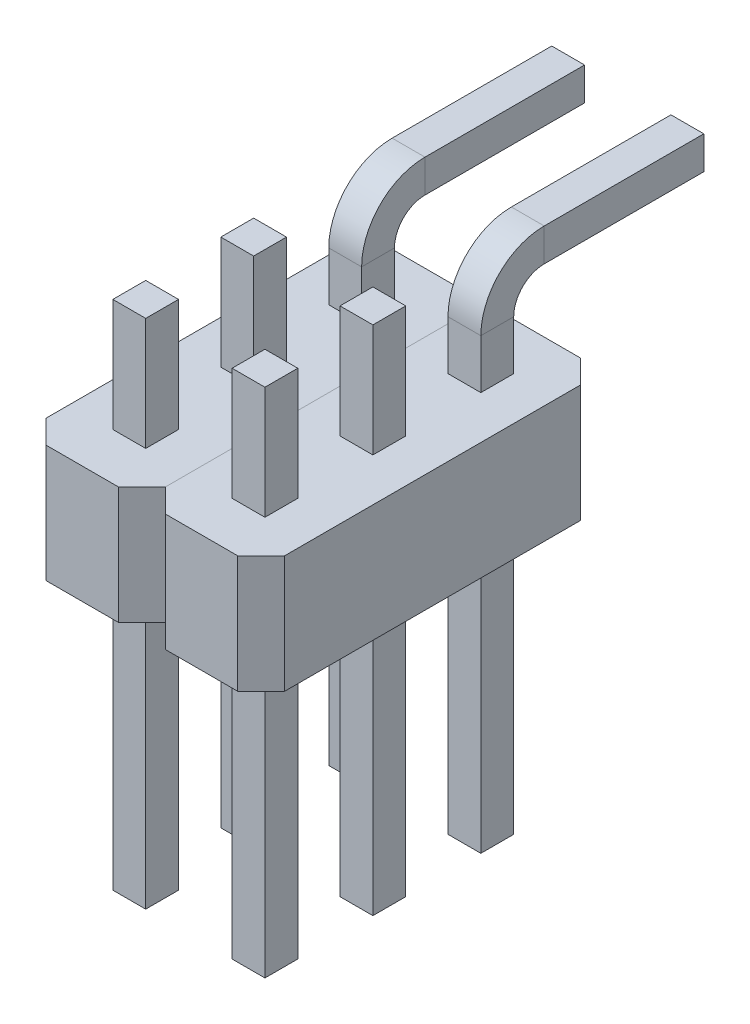
from build123d import *

# Parameters (mm, degrees)
SKETCH1_W           = 0.7
SKETCH1_H           = 0.7
SKETCH1_5_W         = 0.7
SKETCH1_5_H         = 0.7
SKETCH1_6_W         = 0.7
SKETCH1_6_H         = 0.7
SKETCH1_7_W         = 2.54
SKETCH1_7_H         = 7.3
SKETCH1_7_W_2       = 0.7
SKETCH1_7_H_2       = 0.7
BOSS_EXTRUDE1_DEPTH = 2.5
CHAMFER1_SIZE       = 0.5
LPATTERN1_COUNT     = 2
LPATTERN1_PITCH     = 2.54
SKETCH3_W           = 5.08
SKETCH3_H           = 10.35
CUT_EXTRUDE1_DEPTH  = 15.067920955


with BuildPart() as part:
    # Sweep3: sweep along a path in Sketch2
    with BuildLine(Plane(origin=(1.25, 0, 0), x_dir=(0, 0, -1), z_dir=(1, 0, 0))) as sweep3_path:
        Line((-5.95, -6), (-5.95, 8.15))
        ThreePointArc((-5.95, 8.15), (-5.657106781, 8.857106781), (-4.95, 9.15))
        Line((-4.95, 9.15), (3.05, 9.15))
    # Sketch1 → Sweep3 (sweep)
    with BuildSketch(Plane(origin=(0, 0, 0), x_dir=(1, 0, 0), z_dir=(0, 1, 0))):
        with Locations((1.27, -5.95)):
            Rectangle(SKETCH1_W, SKETCH1_H)
    sweep(path=sweep3_path.line)



with BuildPart() as body_2:
    # Sweep4: sweep along a path in Sketch2_6
    with BuildLine(Plane(origin=(1.25, 0, 0), x_dir=(0, 0, -1), z_dir=(1, 0, 0))) as sweep4_path:
        Line((-3.65, -6), (-3.65, 5.85))
        ThreePointArc((-3.65, 5.85), (-3.357106781, 6.557106781), (-2.65, 6.85))
        Line((-2.65, 6.85), (3.05, 6.85))
    # Sketch1_5 → Sweep4 (sweep)
    with BuildSketch(Plane(origin=(0, 0, 0), x_dir=(1, 0, 0), z_dir=(0, 1, 0))):
        with Locations((1.27, -3.65)):
            Rectangle(SKETCH1_5_W, SKETCH1_5_H)
    sweep(path=sweep4_path.line)


with BuildPart() as body_3:
    # Sweep5: sweep along a path in Sketch2_7
    with BuildLine(Plane(origin=(1.25, 0, 0), x_dir=(0, 0, -1), z_dir=(1, 0, 0))) as sweep5_path:
        Line((-1.35, -6), (-1.35, 3.55))
        ThreePointArc((-1.35, 3.55), (-1.057106781, 4.257106781), (-0.35, 4.55))
        Line((-0.35, 4.55), (3.05, 4.55))
    # Sketch1_6 → Sweep5 (sweep)
    with BuildSketch(Plane(origin=(0, 0, 0), x_dir=(1, 0, 0), z_dir=(0, 1, 0))):
        with Locations((1.27, -1.35)):
            Rectangle(SKETCH1_6_W, SKETCH1_6_H)
    sweep(path=sweep5_path.line)


with BuildPart() as part_1:
    add(part.part)

    add(body_2.part)  # Boss-Extrude1 merges body 2

    add(body_3.part)  # Boss-Extrude1 merges body 3
    # Sketch1_7 → Boss-Extrude1 (add)
    with BuildSketch(Plane(origin=(0, 0, 0), x_dir=(1, 0, 0), z_dir=(0, 1, 0))):
        with Locations((1.27, -3.65)):
            Rectangle(SKETCH1_7_W, SKETCH1_7_H)
        with Locations((1.27, -5.95)):
            Rectangle(SKETCH1_7_W_2, SKETCH1_7_H_2, mode=Mode.SUBTRACT)
        with Locations((1.27, -3.65)):
            Rectangle(SKETCH1_7_W_2, SKETCH1_7_H_2, mode=Mode.SUBTRACT)
        with Locations((1.27, -1.35)):
            Rectangle(SKETCH1_7_W_2, SKETCH1_7_H_2, mode=Mode.SUBTRACT)
    extrude(amount=BOSS_EXTRUDE1_DEPTH)

    # Chamfer1
    chamfer1_edges = [part_1.edges().sort_by_distance(p)[0] for p in [
        (0, 1.25, 0),
        (2.54, 1.25, 0),
        (0, 1.25, 7.3),
        (2.54, 1.25, 7.3),
    ]]
    chamfer(chamfer1_edges, length=CHAMFER1_SIZE)


with BuildPart() as lpattern1_1:
    # LPattern1: pattern copy
    add(part_1.part.moved(Location(Vector(1, 0, 0) * (1 * LPATTERN1_PITCH))))


with BuildPart() as cut_extrude1_tool:
    # Sketch3 → Cut-Extrude1 (new, through all)
    with BuildSketch(Plane(origin=(0, 4.9, 0), x_dir=(1, 0, 0), z_dir=(0, 1, 0))):
        with Locations((2.54, -2.125)):
            Rectangle(SKETCH3_W, SKETCH3_H)
    extrude(amount=CUT_EXTRUDE1_DEPTH)


with BuildPart() as part_2:
    add(part_1.part)

    # Cut-Extrude1: cut by cut_extrude1_tool
    add(cut_extrude1_tool.part, mode=Mode.SUBTRACT)


with BuildPart() as lpattern1_1_1:
    add(lpattern1_1.part)

    # Cut-Extrude1: cut by cut_extrude1_tool
    add(cut_extrude1_tool.part, mode=Mode.SUBTRACT)


solid = Compound([part_2.part, lpattern1_1_1.part])
